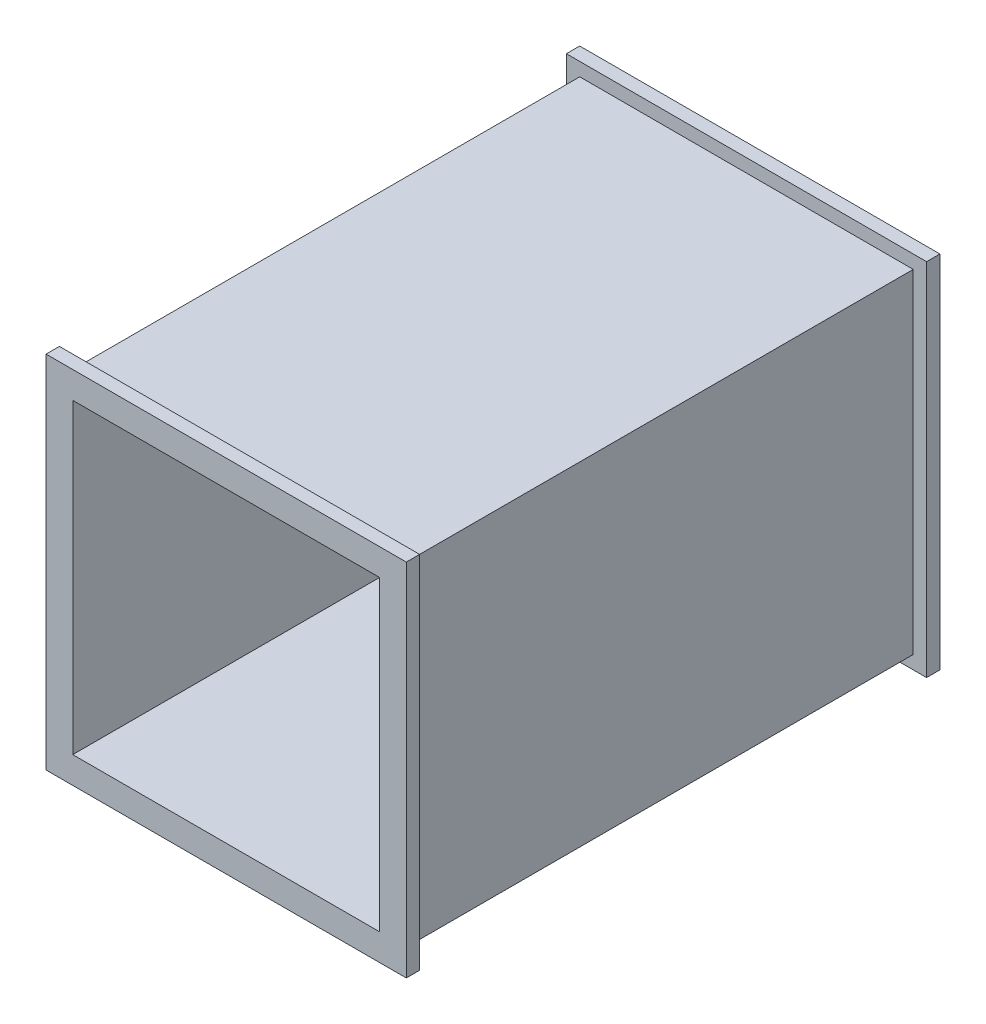
from build123d import *

# Parameters (mm, degrees)
SKETCH2_W           = 125
SKETCH2_H           = 125
BOSS_EXTRUDE1_DEPTH = 200
SHELL1_T            = -5
SKETCH4_W           = 135
SKETCH4_H           = 135
SKETCH4_W_2         = 125
SKETCH4_H_2         = 125
BOSS_EXTRUDE2_DEPTH = 5
SKETCH3_W           = 135
SKETCH3_H           = 135
SKETCH3_W_2         = 125
SKETCH3_H_2         = 125
BOSS_EXTRUDE4_DEPTH = 5


with BuildPart() as part:
    # Sketch2 → Boss-Extrude1 (new body)
    with BuildSketch(Plane.XY):
        Rectangle(SKETCH2_W, SKETCH2_H)
    extrude(amount=BOSS_EXTRUDE1_DEPTH)

    # Shell1
    shell1_openings = [part.faces().sort_by_distance(p)[0] for p in [
        (0, 0, 200),
        (0, 0, 0),
    ]]
    offset(amount=SHELL1_T, openings=shell1_openings, kind=Kind.INTERSECTION)

    # Sketch4 → Boss-Extrude2 (add)
    with BuildSketch(Plane.XY.offset(200)):
        Rectangle(SKETCH4_W, SKETCH4_H)
        Rectangle(SKETCH4_W_2, SKETCH4_H_2, mode=Mode.SUBTRACT)
    extrude(amount=-BOSS_EXTRUDE2_DEPTH)

    # Sketch3 → Boss-Extrude4 (add)
    with BuildSketch(Plane(origin=(0, 0, 0), x_dir=(-1, 0, 0), z_dir=(0, 0, -1))):
        Rectangle(SKETCH3_W, SKETCH3_H)
        Rectangle(SKETCH3_W_2, SKETCH3_H_2, mode=Mode.SUBTRACT)
    extrude(amount=-BOSS_EXTRUDE4_DEPTH)


solid = part.part
